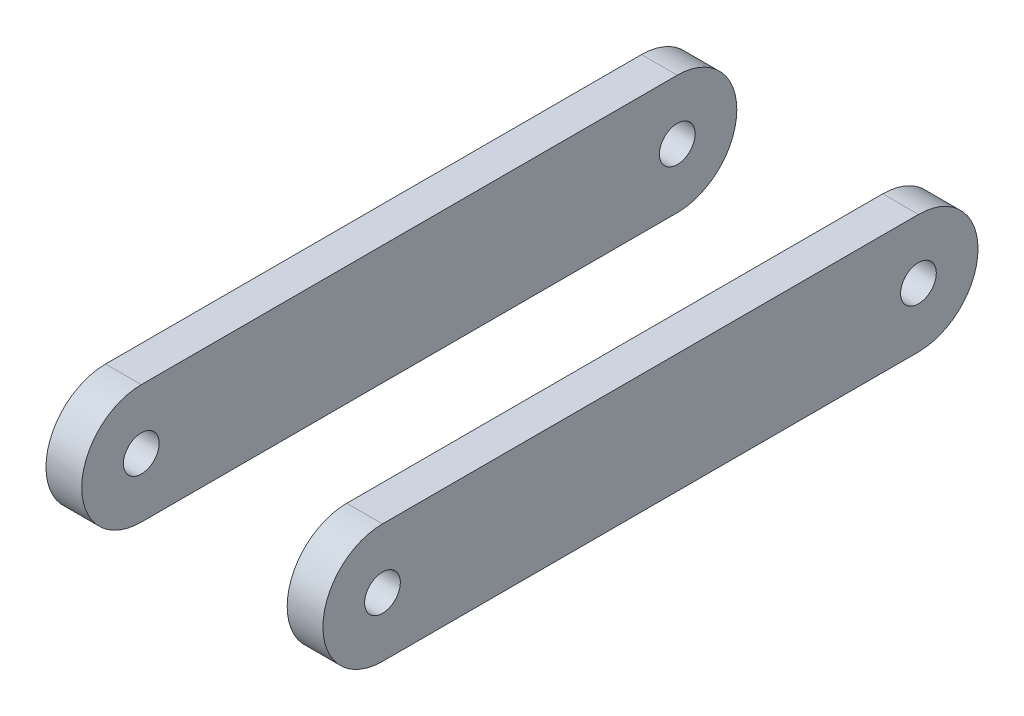
from build123d import *

# Parameters (mm, degrees)
BOSS_EXTRUDE1_DEPTH     = 6
CUT_EXTRUDE1_DEPTH      = 101.677703589
CUT_EXTRUDE1_DEPTH_BACK = 101.677703589
SKETCH2_R               = 3


with BuildPart() as part:
    # Sketch1 → Boss-Extrude1 (new body)
    with BuildSketch(Plane(origin=(17.25, 0, 0), x_dir=(0, 0, -1), z_dir=(1, 0, 0))):
        with BuildLine():
            Line((0, 10), (90, 10))
            ThreePointArc((90, 10), (100, 0), (90, -10))
            Line((90, -10), (0, -10))
            ThreePointArc((0, -10), (-10, 0), (0, 10))
        make_face()
    extrude(amount=BOSS_EXTRUDE1_DEPTH)

    # Sketch2 → Cut-Extrude1 (cut, two sides: drawn at the far end of the back side and taken through both)
    with BuildSketch(Plane(origin=(23.25, 0, 0), x_dir=(0, 0, -1), z_dir=(1, 0, 0)).offset(-CUT_EXTRUDE1_DEPTH_BACK)):
        Circle(SKETCH2_R)
        with Locations((90, 0)):
            Circle(SKETCH2_R)
    extrude(amount=CUT_EXTRUDE1_DEPTH + CUT_EXTRUDE1_DEPTH_BACK, mode=Mode.SUBTRACT)


with BuildPart() as body_2:
    # Mirror4: mirrored copy
    add(part.part.mirror(Plane(origin=(0, 0, 0), x_dir=(0, 0, 1), z_dir=(1, 0, 0))))


solid = Compound([part.part, body_2.part])
